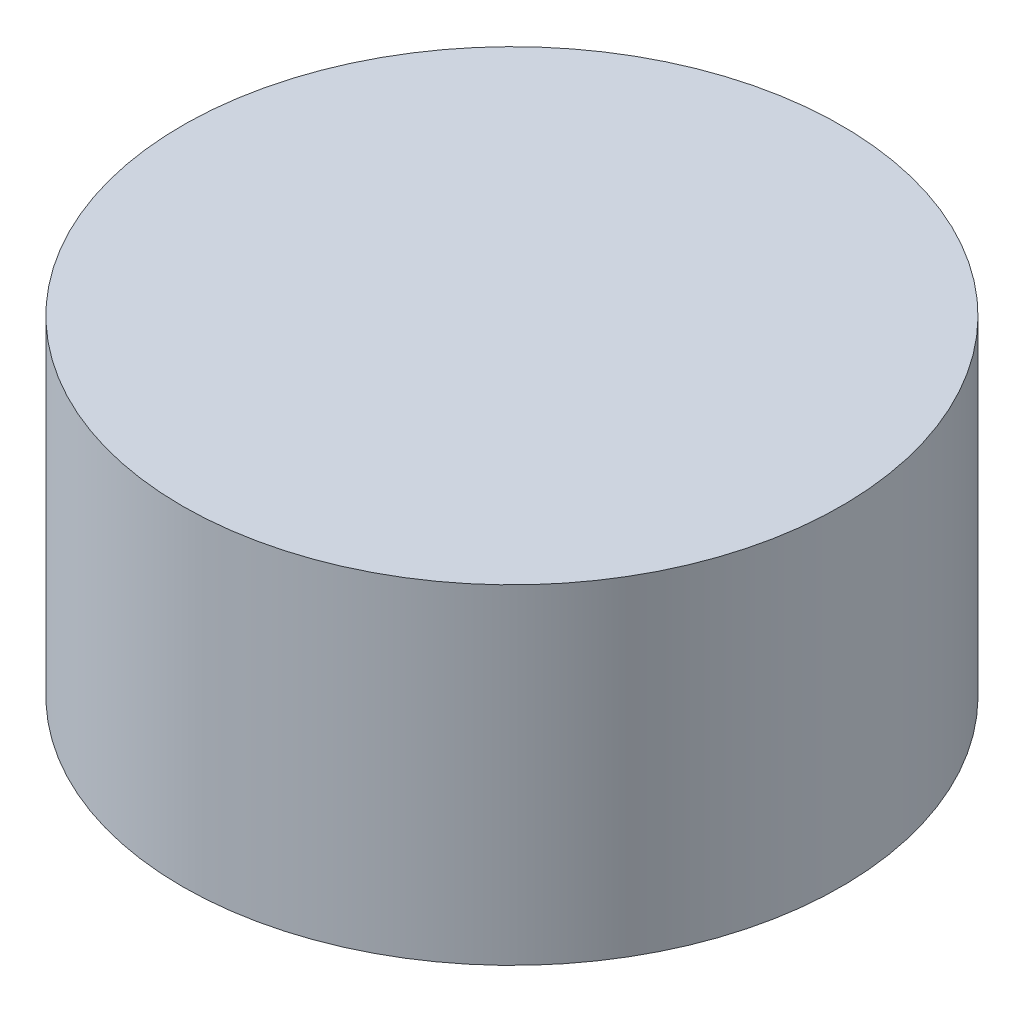
from build123d import *

# Parameters (mm, degrees)
CROQUIS1_R              = 3
SALIENTE_EXTRUIR1_DEPTH = 3


with BuildPart() as part:
    # Croquis1 → Saliente-Extruir1 (new body)
    with BuildSketch(Plane(origin=(0, 0, 0), x_dir=(1, 0, 0), z_dir=(0, 1, 0))):
        Circle(CROQUIS1_R)
    extrude(amount=SALIENTE_EXTRUIR1_DEPTH)


solid = part.part
